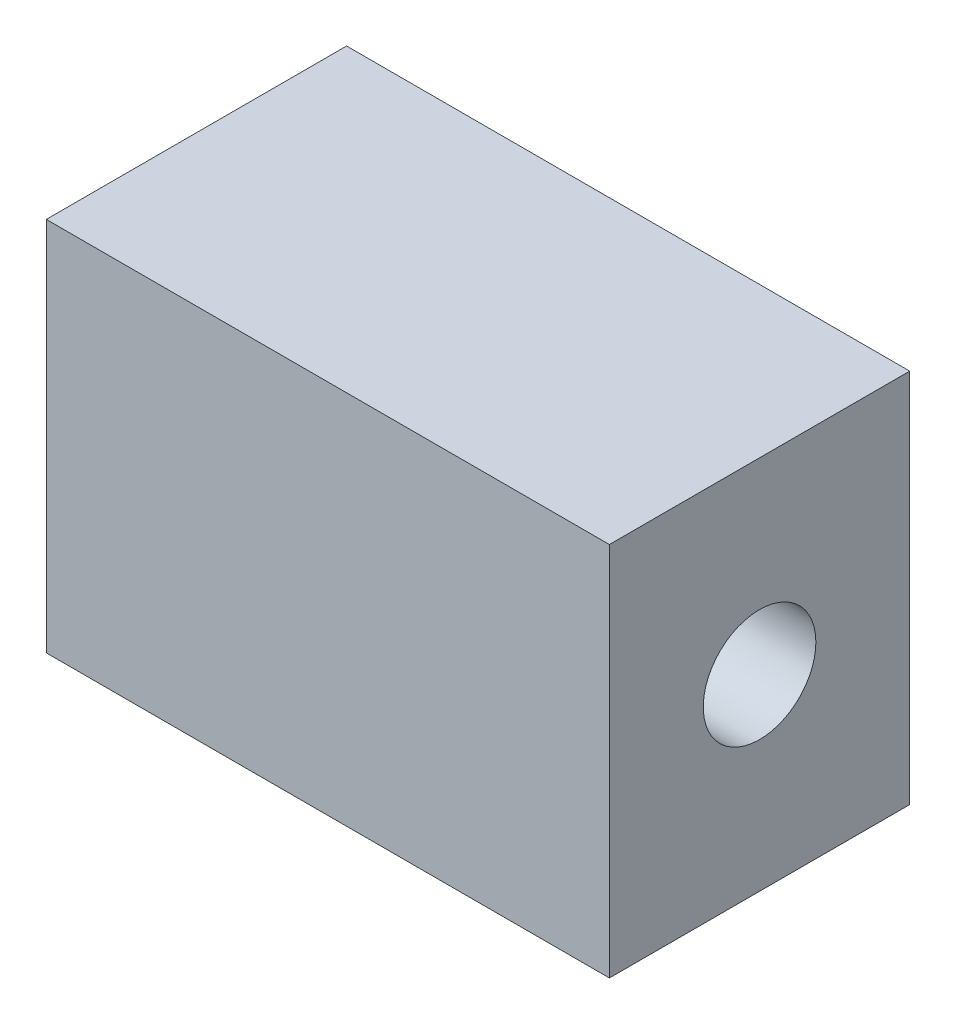
from build123d import *

# Parameters (mm, degrees)
SKETCH1_W           = 15
SKETCH1_H           = 10
BOSS_EXTRUDE2_DEPTH = 8
SKETCH2_R           = 1.5
CUT_EXTRUDE1_DEPTH  = 15


with BuildPart() as part:
    # Sketch1 → Boss-Extrude2 (new body)
    with BuildSketch(Plane.XY):
        with Locations((-4.137554585, 4.497816594)):
            Rectangle(SKETCH1_W, SKETCH1_H)
    extrude(amount=BOSS_EXTRUDE2_DEPTH)

    # Sketch2 → Cut-Extrude1 (cut)
    with BuildSketch(Plane(origin=(3.362445415, 0, 0), x_dir=(0, 0, -1), z_dir=(1, 0, 0))):
        with Locations((-4, 4.497816594)):
            Circle(SKETCH2_R)
    extrude(amount=-CUT_EXTRUDE1_DEPTH, mode=Mode.SUBTRACT)


solid = part.part
